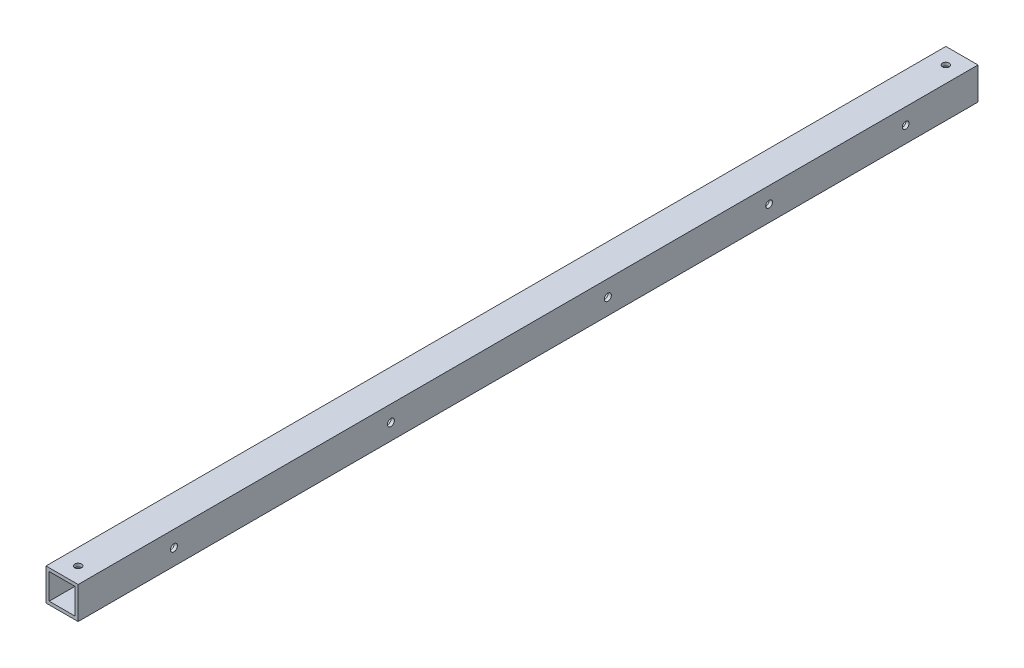
from build123d import *

# Parameters (mm, degrees)
SKETCH_1_W          = 20
SKETCH_1_H          = 20
SKETCH_1_W_2        = 16
SKETCH_1_H_2        = 16
EXTRUDE_1_DEPTH     = 560
SKETCH_2_R          = 2.1
CUT_EXTRUDE_1_DEPTH = 10
SKETCH_4_R          = 2.2
CUT_EXTRUDE_3_DEPTH = 21
SKETCH_5_R          = 2.1
CUT_EXTRUDE_4_DEPTH = 22


with BuildPart() as part:
    # ｽｹｯﾁ1 → ﾎﾞｽ - 押し出し1 (new body)
    with BuildSketch(Plane.XY):
        Rectangle(SKETCH_1_W, SKETCH_1_H)
        Rectangle(SKETCH_1_W_2, SKETCH_1_H_2, mode=Mode.SUBTRACT)
    extrude(amount=EXTRUDE_1_DEPTH)

    # ｽｹｯﾁ2 → ｶｯﾄ - 押し出し1 (cut)
    with BuildSketch(Plane(origin=(0, 10, 0), x_dir=(1, 0, 0), z_dir=(0, 1, 0))):
        with Locations((0, -550)):
            Circle(SKETCH_2_R)
        with Locations((0, -10)):
            Circle(SKETCH_2_R)
    extrude(amount=-CUT_EXTRUDE_1_DEPTH, mode=Mode.SUBTRACT)

    # ｽｹｯﾁ4 → ｶｯﾄ - 押し出し3 (cut, through all)
    with BuildSketch(Plane(origin=(10, 0, 0), x_dir=(0, 0, -1), z_dir=(1, 0, 0))):
        with Locations((-500.38, 0)):
            Circle(SKETCH_4_R)
        with Locations((-365.38, 0)):
            Circle(SKETCH_4_R)
        with Locations((-230.38, 0)):
            Circle(SKETCH_4_R)
    extrude(amount=-CUT_EXTRUDE_3_DEPTH, mode=Mode.SUBTRACT)

    # ｽｹｯﾁ5 → ｶｯﾄ - 押し出し4 (cut)
    with BuildSketch(Plane(origin=(10, 0, 0), x_dir=(0, 0, -1), z_dir=(1, 0, 0))):
        with Locations((-130, 0)):
            Circle(SKETCH_5_R)
        with Locations((-45, 0)):
            Circle(SKETCH_5_R)
    extrude(amount=-CUT_EXTRUDE_4_DEPTH, mode=Mode.SUBTRACT)


solid = part.part
